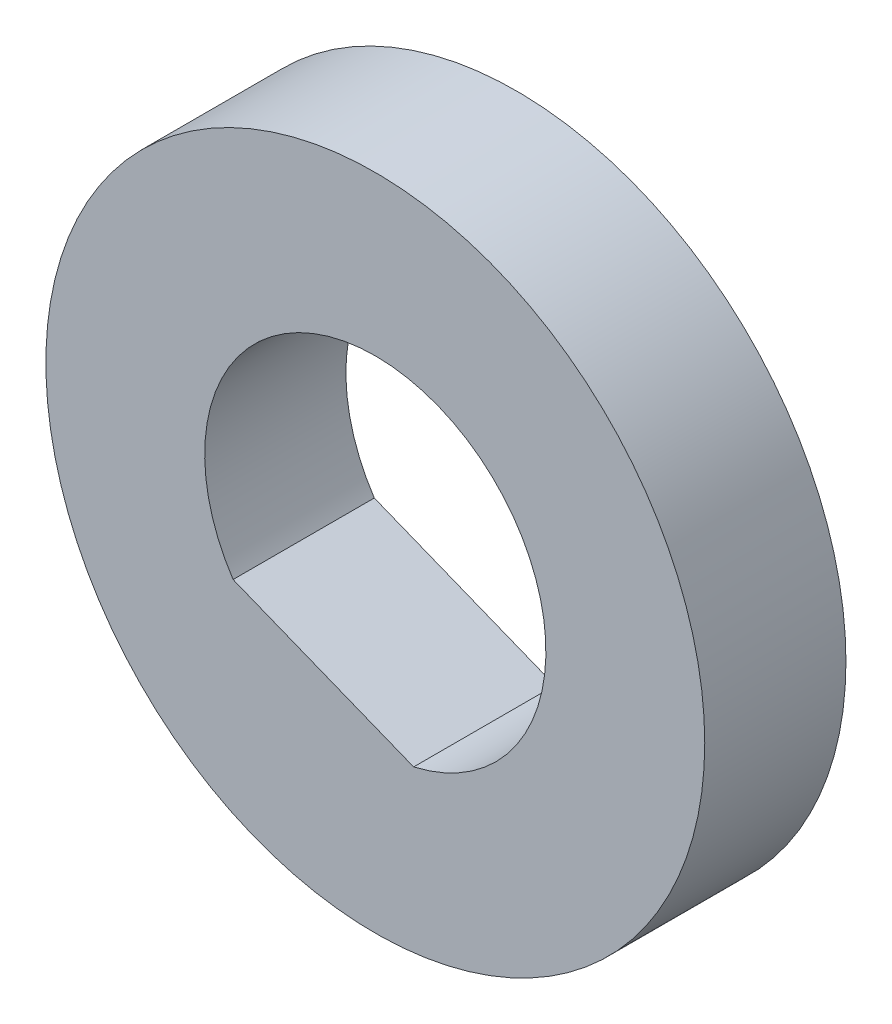
from build123d import *

# Parameters (mm, degrees)
ESQUISSE1_R             = 14
BOSS_EXTRU_1_DEPTH      = 6
ENL_V_MAT_EXTRU_1_DEPTH = 16


with BuildPart() as part:
    # Esquisse1 → Boss.-Extru.1 (new body)
    with BuildSketch(Plane.XY):
        Circle(ESQUISSE1_R)
    extrude(amount=BOSS_EXTRU_1_DEPTH)

    # Esquisse2 → Enlèv. mat.-Extru.1 (cut)
    with BuildSketch(Plane.XY):
        with BuildLine():
            Line((1.628624847, -7.064706725), (-6.043630687, -4.00462584))
            ThreePointArc((-6.043630687, -4.00462584), (2.685906345, 6.734122594), (1.628624847, -7.064706725))
        make_face()
    extrude(amount=ENL_V_MAT_EXTRU_1_DEPTH, mode=Mode.SUBTRACT)


solid = part.part
